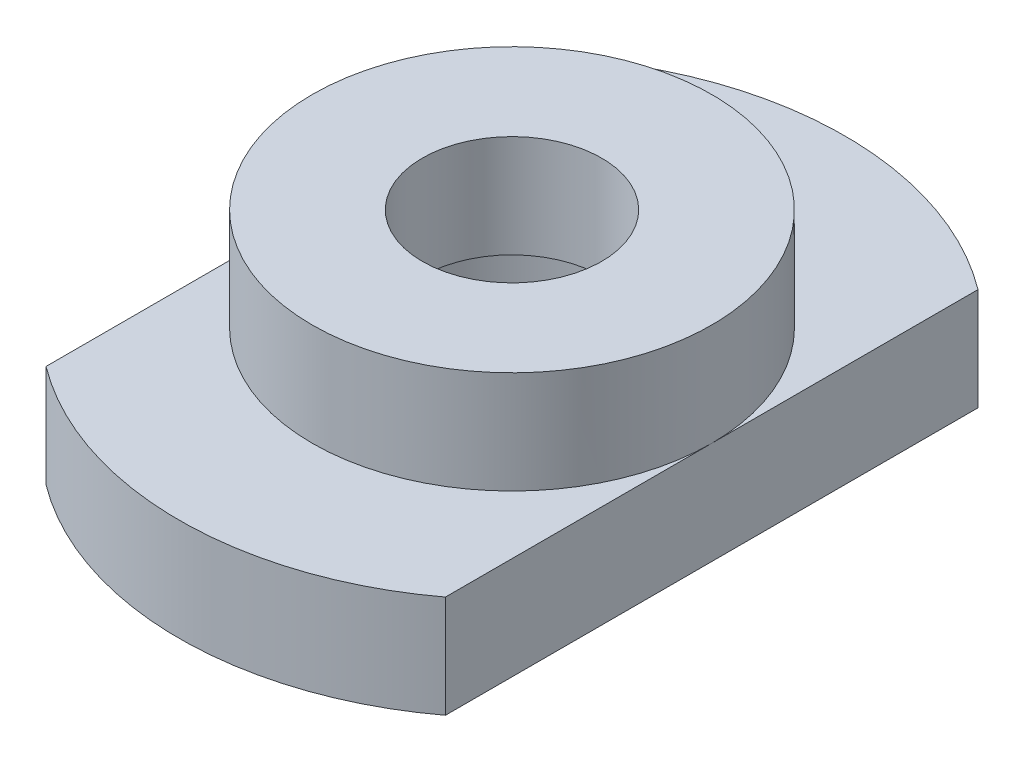
from build123d import *

# Parameters (mm, degrees)
SKETCH2_R           = 2.9
BOSS_EXTRUDE1_DEPTH = 2
SKETCH3_R           = 3.9
SKETCH3_R_2         = 2.9
SKETCH3_R_3         = 1.75
BOSS_EXTRUDE2_DEPTH = 2


with BuildPart() as part:
    # Sketch2 → Boss-Extrude1 (new body)
    with BuildSketch(Plane(origin=(0, 0, 0), x_dir=(1, 0, 0), z_dir=(0, 1, 0))):
        with BuildLine():
            ThreePointArc((3.9, 5.2), (0, 6.5), (-3.9, 5.2))
            Line((-3.9, 5.2), (-3.9, -5.2))
            ThreePointArc((-3.9, -5.2), (0, -6.5), (3.9, -5.2))
            Line((3.9, -5.2), (3.9, 5.2))
        make_face()
        Circle(SKETCH2_R, mode=Mode.SUBTRACT)
    extrude(amount=BOSS_EXTRUDE1_DEPTH)

    # Sketch3 → Boss-Extrude2 (add)
    with BuildSketch(Plane(origin=(0, 2, 0), x_dir=(1, 0, 0), z_dir=(0, 1, 0))):
        Circle(SKETCH3_R)
        Circle(SKETCH3_R_2, mode=Mode.SUBTRACT)
        Circle(SKETCH3_R_2)
        Circle(SKETCH3_R_3, mode=Mode.SUBTRACT)
    extrude(amount=BOSS_EXTRUDE2_DEPTH)


solid = part.part
